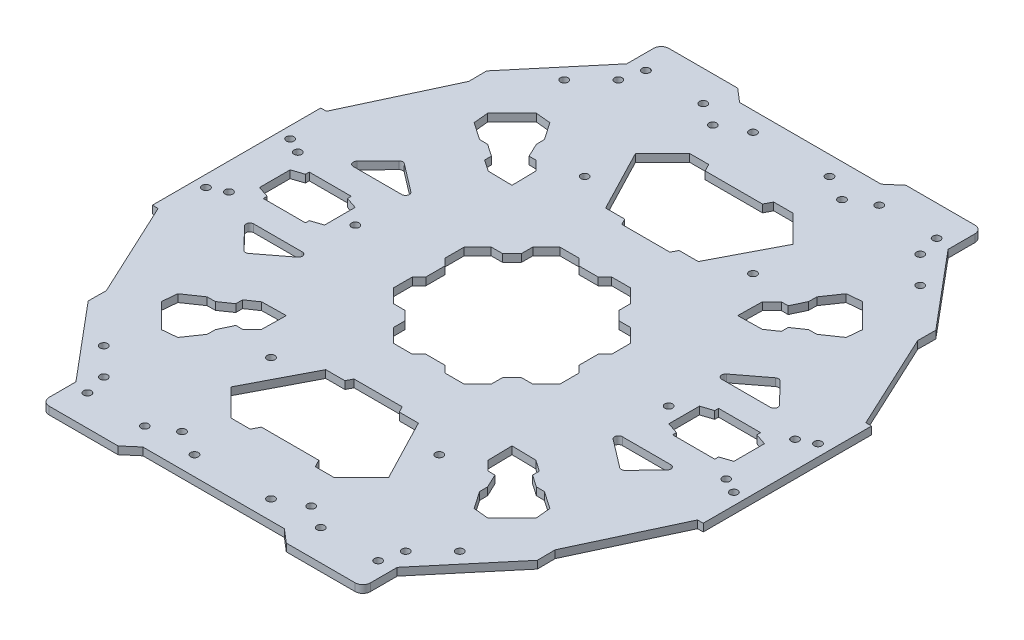
from build123d import *
from build123d.topology import SkipClean

# Parameters (mm, degrees)
SKETCH2_R                                  = 1
BOSS_EXTRUDE1_DEPTH                        = 2
MIRROR2_AT_THE_SECOND_PLANE_COPY_1_SKETC_R = 1
MIRROR2_AT_THE_SECOND_PLANE_COPY_1_DEPTH   = 2


with BuildPart() as part:
    # Sketch2 → Boss-Extrude1 (new body)
    with BuildSketch(Plane(origin=(0, 0, 0), x_dir=(1, 0, 0), z_dir=(0, 1, 0))):
        with BuildLine():
            Line((0, 58), (0, 78))
            Line((0, 78), (-18.5, 78))
            Line((-18.5, 78), (-22, 81))
            Line((-22, 81), (-40, 81))
            ThreePointArc((-40, 81), (-41.414213562, 80.414213562), (-42, 79))
            Line((-42, 79), (-42, 72))
            Line((-42, 72), (-58.712477852, 52.082844479))
            Line((-58.712477852, 52.082844479), (-58.668059631, 47.390805138))
            Line((-58.668059631, 47.390805138), (-70.501370959, 22.014187101))
            Line((-70.501370959, 22.014187101), (-72, 22))
            Line((-72, 22), (-72, 0))
            Line((-72, 0), (-62, 0))
            Line((-62, 0), (-62, 4))
            Line((-62, 4), (-59, 5))
            Line((-59, 5), (-59, 6))
            Line((-59, 6), (-48, 6))
            Line((-48, 6), (-48, 5))
            Line((-48, 5), (-45, 4))
            Line((-45, 4), (-45, 0))
            Line((-45, 0), (-41.957469428, 0))
            ThreePointArc((-41.957469428, 0), (-40.957469428, 1), (-39.957469428, 0))
            Line((-39.957469428, 0), (-20, 0))
            Line((-20, 0), (-20, 2.5))
            Line((-20, 2.5), (-21.767766953, 4.267766953))
            Line((-21.767766953, 4.267766953), (-21.767766953, 9.267766953))
            Line((-21.767766953, 9.267766953), (-18.232233047, 12.803300859))
            Line((-18.232233047, 12.803300859), (-15.232233047, 12.803300859))
            Line((-15.232233047, 12.803300859), (-12.803300859, 15.232233047))
            Line((-12.803300859, 15.232233047), (-12.803300859, 18.232233047))
            Line((-12.803300859, 18.232233047), (-9.267766953, 21.767766953))
            Line((-9.267766953, 21.767766953), (-4.267766953, 21.767766953))
            Line((-4.267766953, 21.767766953), (-2.5, 20))
            Line((-2.5, 20), (0, 20))
            Line((0, 20), (0, 35))
            Line((0, 35), (-6.286398777, 35))
            Line((-6.286398777, 35), (-7.109651615, 36.582868135))
            Line((-7.109651615, 36.582868135), (-12.109651615, 36.582868135))
            Line((-12.109651615, 36.582868135), (-20.571067812, 52.851632072))
            Line((-20.571067812, 52.851632072), (-13.5, 59.922699883))
            Line((-13.5, 59.922699883), (-8.5, 59.922699883))
            Line((-8.5, 59.922699883), (-7.5, 58))
            Line((-7.5, 58), (0, 58))
        make_face()
        with Locations(Location((-65, 9, 0), (0, 0, 270))):
            Circle(SKETCH2_R, mode=Mode.SUBTRACT)
        with Locations(Location((-69, 11, 0), (0, 0, 270))):
            Circle(SKETCH2_R, mode=Mode.SUBTRACT)
        with BuildLine():
            Line((-41.839840722, 13), (-54.515368917, 13))
            ThreePointArc((-54.515368917, 13), (-55.43650129, 13.610750528), (-55.232469497, 14.696969697))
            Line((-55.232469497, 14.696969697), (-49.833633414, 20.251742741))
            ThreePointArc((-49.833633414, 20.251742741), (-49.190282447, 20.552049833), (-48.50975542, 20.349644839))
            Line((-48.50975542, 20.349644839), (-41.233063308, 14.794871795))
            ThreePointArc((-41.233063308, 14.794871795), (-40.892509789, 13.679743692), (-41.839840722, 13))
        make_face(mode=Mode.SUBTRACT)
        Polygon((-48.630106489, 38.730611552), (-49.00437522, 42.64041419), (-42.64041419, 49.00437522), (-38.730611552, 48.630106489), (-35.620672262, 44.105953636), (-35.581831384, 41.945792414), (-33.875458568, 38.327994412), (-32.107711092, 38.327994412), (-29.61074684, 35.83103016), (-29.496854911, 29.496854911), (-35.83103016, 29.61074684), (-38.790556383, 31.645149121), (-38.790556383, 33.412896597), (-41.945792414, 35.581831384), (-44.105953636, 35.620672262), align=None, mode=Mode.SUBTRACT)
        with Locations(Location((-46.526420816, 60.182905253, 0), (0, 0, 270))):
            Circle(SKETCH2_R, mode=Mode.SUBTRACT)
        with Locations(Location((-39.455353004, 67.253973065, 0), (0, 0, 270))):
            Circle(SKETCH2_R, mode=Mode.SUBTRACT)
        with Locations(Location((-38, 73, 0), (0, 0, 270))):
            Circle(SKETCH2_R, mode=Mode.SUBTRACT)
        with Locations(Location((-22, 41, 0), (0, 0, 270))):
            Circle(SKETCH2_R, mode=Mode.SUBTRACT)
        with Locations(Location((-23, 73, 0), (0, 0, 270))):
            Circle(SKETCH2_R, mode=Mode.SUBTRACT)
        with Locations(Location((-16.882181673, 69.385939502, 0), (0, 0, 270))):
            Circle(SKETCH2_R, mode=Mode.SUBTRACT)
        with Locations(Location((-10, 73, 0), (0, 0, 270))):
            Circle(SKETCH2_R, mode=Mode.SUBTRACT)
    boss_extrude1 = extrude(amount=BOSS_EXTRUDE1_DEPTH)

    # Mirror2 at the second plane: Boss-Extrude1 across plane
    add(boss_extrude1.mirror(Plane.XY))



with BuildPart() as mirror2_1:
    # Mirror2: Boss-Extrude1 across plane
    add(boss_extrude1.mirror(Plane(origin=(0, 0, 0), x_dir=(0, 0, 1), z_dir=(1, 0, 0))))


with BuildPart() as part_1:
    with SkipClean():  # the faces are left unmerged after this step: merging them gives an invalid solid
        add(part.part)

        add(mirror2_1.part)  # Mirror2 at the second plane copy 1 merges Mirror2_1
        # Mirror2 at the second plane copy 1 sketc → Mirror2 at the second plane copy 1 (add)
        with BuildSketch(Plane(origin=(0, 0, 0), x_dir=(-1, 0, 0), z_dir=(0, 1, 0))):
            with BuildLine():
                Line((0, 58), (0, 78))
                Line((0, 78), (-18.5, 78))
                Line((-18.5, 78), (-22, 81))
                Line((-22, 81), (-40, 81))
                ThreePointArc((-40, 81), (-41.414213562, 80.414213562), (-42, 79))
                Line((-42, 79), (-42, 72))
                Line((-42, 72), (-58.712477852, 52.082844479))
                Line((-58.712477852, 52.082844479), (-58.668059631, 47.390805138))
                Line((-58.668059631, 47.390805138), (-70.501370959, 22.014187101))
                Line((-70.501370959, 22.014187101), (-72, 22))
                Line((-72, 22), (-72, 0))
                Line((-72, 0), (-62, 0))
                Line((-62, 0), (-62, 4))
                Line((-62, 4), (-59, 5))
                Line((-59, 5), (-59, 6))
                Line((-59, 6), (-48, 6))
                Line((-48, 6), (-48, 5))
                Line((-48, 5), (-45, 4))
                Line((-45, 4), (-45, 0))
                Line((-45, 0), (-41.957469428, 0))
                ThreePointArc((-41.957469428, 0), (-40.957469428, 1), (-39.957469428, 0))
                Line((-39.957469428, 0), (-20, 0))
                Line((-20, 0), (-20, 2.5))
                Line((-20, 2.5), (-21.767766953, 4.267766953))
                Line((-21.767766953, 4.267766953), (-21.767766953, 9.267766953))
                Line((-21.767766953, 9.267766953), (-18.232233047, 12.803300859))
                Line((-18.232233047, 12.803300859), (-15.232233047, 12.803300859))
                Line((-15.232233047, 12.803300859), (-12.803300859, 15.232233047))
                Line((-12.803300859, 15.232233047), (-12.803300859, 18.232233047))
                Line((-12.803300859, 18.232233047), (-9.267766953, 21.767766953))
                Line((-9.267766953, 21.767766953), (-4.267766953, 21.767766953))
                Line((-4.267766953, 21.767766953), (-2.5, 20))
                Line((-2.5, 20), (0, 20))
                Line((0, 20), (0, 35))
                Line((0, 35), (-6.286398777, 35))
                Line((-6.286398777, 35), (-7.109651615, 36.582868135))
                Line((-7.109651615, 36.582868135), (-12.109651615, 36.582868135))
                Line((-12.109651615, 36.582868135), (-20.571067812, 52.851632072))
                Line((-20.571067812, 52.851632072), (-13.5, 59.922699883))
                Line((-13.5, 59.922699883), (-8.5, 59.922699883))
                Line((-8.5, 59.922699883), (-7.5, 58))
                Line((-7.5, 58), (0, 58))
            make_face()
            with Locations(Location((-65, 9, 0), (0, 0, 270))):
                Circle(MIRROR2_AT_THE_SECOND_PLANE_COPY_1_SKETC_R, mode=Mode.SUBTRACT)
            with Locations(Location((-69, 11, 0), (0, 0, 270))):
                Circle(MIRROR2_AT_THE_SECOND_PLANE_COPY_1_SKETC_R, mode=Mode.SUBTRACT)
            with BuildLine():
                Line((-41.839840722, 13), (-54.515368917, 13))
                ThreePointArc((-54.515368917, 13), (-55.43650129, 13.610750528), (-55.232469497, 14.696969697))
                Line((-55.232469497, 14.696969697), (-49.833633414, 20.251742741))
                ThreePointArc((-49.833633414, 20.251742741), (-49.190282447, 20.552049833), (-48.50975542, 20.349644839))
                Line((-48.50975542, 20.349644839), (-41.233063308, 14.794871795))
                ThreePointArc((-41.233063308, 14.794871795), (-40.892509789, 13.679743692), (-41.839840722, 13))
            make_face(mode=Mode.SUBTRACT)
            Polygon((-48.630106489, 38.730611552), (-49.00437522, 42.64041419), (-42.64041419, 49.00437522), (-38.730611552, 48.630106489), (-35.620672262, 44.105953636), (-35.581831384, 41.945792414), (-33.875458568, 38.327994412), (-32.107711092, 38.327994412), (-29.61074684, 35.83103016), (-29.496854911, 29.496854911), (-35.83103016, 29.61074684), (-38.790556383, 31.645149121), (-38.790556383, 33.412896597), (-41.945792414, 35.581831384), (-44.105953636, 35.620672262), align=None, mode=Mode.SUBTRACT)
            with Locations(Location((-46.526420816, 60.182905253, 0), (0, 0, 270))):
                Circle(MIRROR2_AT_THE_SECOND_PLANE_COPY_1_SKETC_R, mode=Mode.SUBTRACT)
            with Locations(Location((-39.455353004, 67.253973065, 0), (0, 0, 270))):
                Circle(MIRROR2_AT_THE_SECOND_PLANE_COPY_1_SKETC_R, mode=Mode.SUBTRACT)
            with Locations(Location((-38, 73, 0), (0, 0, 270))):
                Circle(MIRROR2_AT_THE_SECOND_PLANE_COPY_1_SKETC_R, mode=Mode.SUBTRACT)
            with Locations(Location((-22, 41, 0), (0, 0, 270))):
                Circle(MIRROR2_AT_THE_SECOND_PLANE_COPY_1_SKETC_R, mode=Mode.SUBTRACT)
            with Locations(Location((-23, 73, 0), (0, 0, 270))):
                Circle(MIRROR2_AT_THE_SECOND_PLANE_COPY_1_SKETC_R, mode=Mode.SUBTRACT)
            with Locations(Location((-16.882181673, 69.385939502, 0), (0, 0, 270))):
                Circle(MIRROR2_AT_THE_SECOND_PLANE_COPY_1_SKETC_R, mode=Mode.SUBTRACT)
            with Locations(Location((-10, 73, 0), (0, 0, 270))):
                Circle(MIRROR2_AT_THE_SECOND_PLANE_COPY_1_SKETC_R, mode=Mode.SUBTRACT)
        extrude(amount=MIRROR2_AT_THE_SECOND_PLANE_COPY_1_DEPTH)


solid = part_1.part
